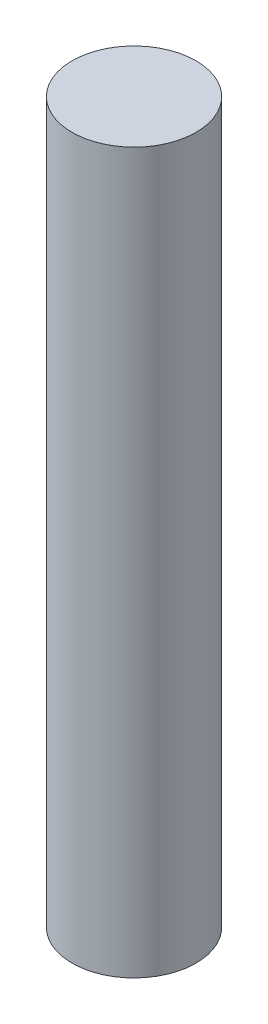
from build123d import *


with BuildPart() as part:
    # Sketch1 → Revolve1 (revolve)
    with BuildSketch(Plane.XY):
        Polygon((0, 0), (0, 39.16173258), (7, 39.16173258), (7, -42.06826742), (0, -42.06826742), align=None)
    revolve(axis=Axis((0, 0, 0), (0, 1, 0)))


solid = part.part
